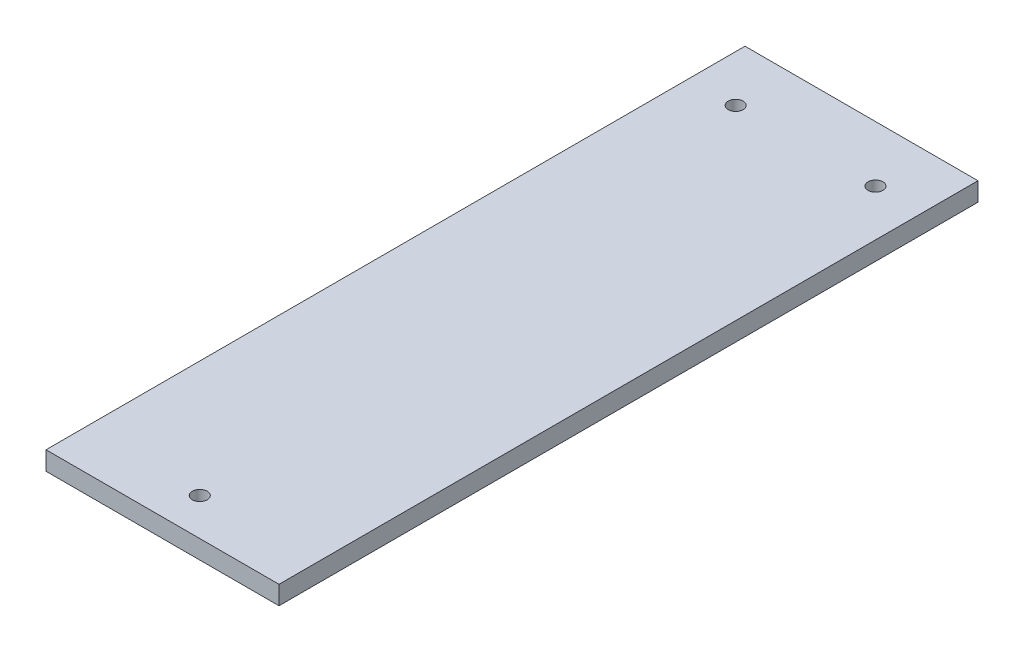
from build123d import *

# Parameters (mm, degrees)
SKETCH_1_W      = 50
SKETCH_1_H      = 150
SKETCH_1_R      = 1.6
EXTRUDE_1_DEPTH = 4


with BuildPart() as part:
    # 草图1 → 凸台-拉伸1 (new body)
    with BuildSketch(Plane(origin=(0, 0, 0), x_dir=(1, 0, 0), z_dir=(0, 1, 0))):
        Rectangle(SKETCH_1_W, SKETCH_1_H)
        with Locations((-15, 63)):
            Circle(SKETCH_1_R, mode=Mode.SUBTRACT)
        with Locations((15, 63)):
            Circle(SKETCH_1_R, mode=Mode.SUBTRACT)
        with Locations((0, -67)):
            Circle(SKETCH_1_R, mode=Mode.SUBTRACT)
    extrude(amount=EXTRUDE_1_DEPTH)


solid = part.part
